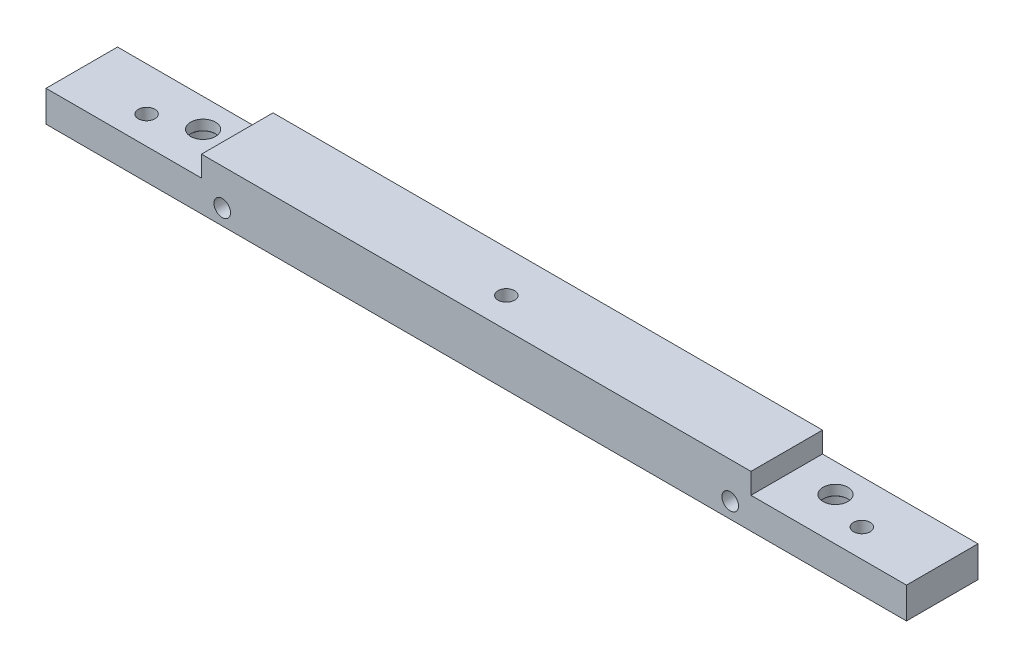
from build123d import *

# Parameters (mm, degrees)
BOSS_EXTRUDE1_DEPTH                            = 8.5
CBORE_FOR_M2_SOCKET_HEAD_CAP_SCREW1_AT_2_COUNT = 2
CBORE_FOR_M2_SOCKET_HEAD_CAP_SCREW1_AT_2_PITCH = 61
SKETCH8_W                                      = 53
SKETCH8_H                                      = 1
CUT_EXTRUDE1_DEPTH                             = 9.5
M2X0_4_TAPPED_HOLE8_D                          = 1.6
SKETCH14_W                                     = 83
SKETCH14_H                                     = 1.6
CUT_EXTRUDE2_DEPTH                             = 10
M2X0_4_TAPPED_HOLE7_D                          = 1.6
M2X0_4_TAPPED_HOLE6_D                          = 1.6
M2X0_4_TAPPED_HOLE6_DEPTH                      = 5.2
M2X0_4_TAPPED_HOLE6_TIP                        = 0.480688495


with BuildPart() as part:
    # Sketch1 → Boss-Extrude1 (new body)
    with BuildSketch(Plane.XY):
        Polygon((53, -3), (68, -3), (68, -6), (-15, -6), (-15, -3), (0, -3), (0, 0), (53, 0), align=None)
    extrude(amount=BOSS_EXTRUDE1_DEPTH)

    # Sketch4 → CBORE for M2 Socket Head Cap Screw1 (revolve, cut)
    with BuildSketch(Plane(origin=(-4, -6, 2.75), x_dir=(0, 0, -1), z_dir=(1, 0, 0))):
        Polygon((0, 0), (0, 6), (1.2, 6), (1.2, 2.025), (1.225, 2), (2.2, 2), (2.2, 0), align=None)
    cbore_for_m2_socket_head_cap_screw1 = revolve(axis=Axis((-4, -12.35, 2.75), (0, 1, 0)), mode=Mode.SUBTRACT)

    # CBORE for M2 Socket Head Cap Screw1 at 2: CBORE for M2 Socket Head Cap Screw1 ×2
    with Locations(*[(i * CBORE_FOR_M2_SOCKET_HEAD_CAP_SCREW1_AT_2_PITCH, 0, 0) for i in range(1, CBORE_FOR_M2_SOCKET_HEAD_CAP_SCREW1_AT_2_COUNT)]):
        add(cbore_for_m2_socket_head_cap_screw1, mode=Mode.SUBTRACT)

    # Sketch8 → Cut-Extrude1 (cut, through all)
    with BuildSketch(Plane.XY.offset(8.5)):
        with Locations((26.5, -0.5)):
            Rectangle(SKETCH8_W, SKETCH8_H)
    extrude(amount=-CUT_EXTRUDE1_DEPTH, mode=Mode.SUBTRACT)

    # M2x0.4 Tapped Hole8 (through all)
    with Locations(Plane.XY.offset(8.5)):
        with Locations((2, -4.5), (51, -4.5)):
            Hole(M2X0_4_TAPPED_HOLE8_D / 2)

    # Sketch14 → Cut-Extrude2 (cut)
    with BuildSketch(Plane.XZ.offset(6)):
        with Locations((26.5, 7.7)):
            Rectangle(SKETCH14_W, SKETCH14_H)
    extrude(amount=-CUT_EXTRUDE2_DEPTH, mode=Mode.SUBTRACT)

    # M2x0.4 Tapped Hole7 (through all)
    with Locations(Plane(origin=(0, -6, 0), x_dir=(-1, 0, 0), z_dir=(0, -1, 0))):
        with Locations((8, -4.2), (-61, -4.2)):
            Hole(M2X0_4_TAPPED_HOLE7_D / 2)

    # M2x0.4 Tapped Hole6
    with Locations(Plane(origin=(0, -6, 0), x_dir=(-1, 0, 0), z_dir=(0, -1, 0))):
        with Locations((-26.5, -4)):
            Hole(M2X0_4_TAPPED_HOLE6_D / 2, depth=M2X0_4_TAPPED_HOLE6_DEPTH)
            with Locations((0, 0, -(M2X0_4_TAPPED_HOLE6_DEPTH + M2X0_4_TAPPED_HOLE6_TIP / 2))):  # 118° drill point
                Cone(0, M2X0_4_TAPPED_HOLE6_D / 2, M2X0_4_TAPPED_HOLE6_TIP, mode=Mode.SUBTRACT)


solid = part.part
